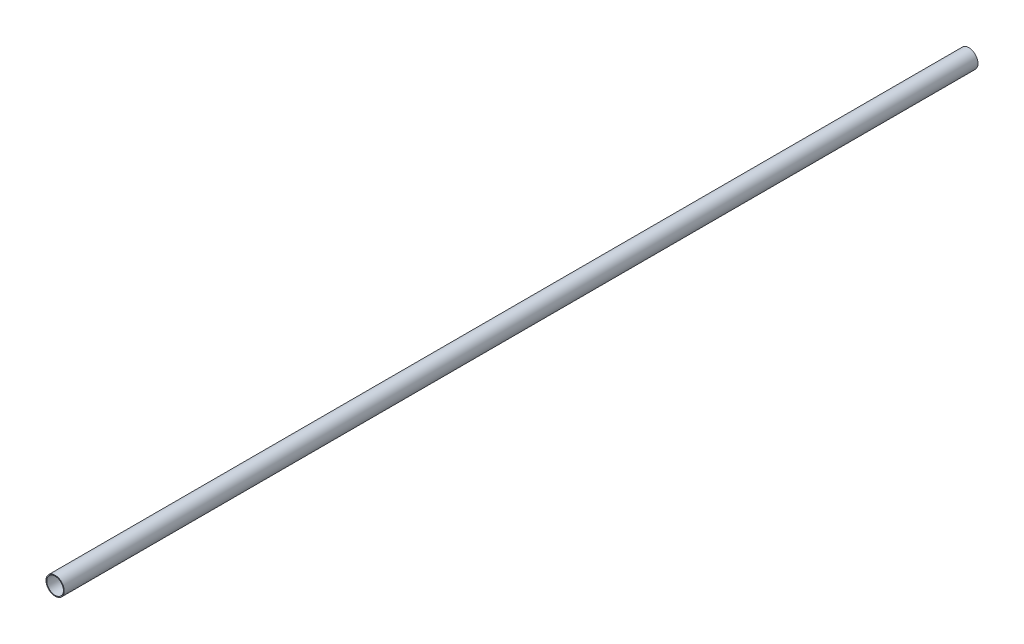
from build123d import *

# Parameters (mm, degrees)
SKETCH1_R           = 11
SKETCH1_R_2         = 10
BOSS_EXTRUDE1_DEPTH = 1100


with BuildPart() as part:
    # Sketch1 → Boss-Extrude1 (new body)
    with BuildSketch(Plane.XY):
        Circle(SKETCH1_R)
        Circle(SKETCH1_R_2, mode=Mode.SUBTRACT)
    extrude(amount=BOSS_EXTRUDE1_DEPTH)


solid = part.part
